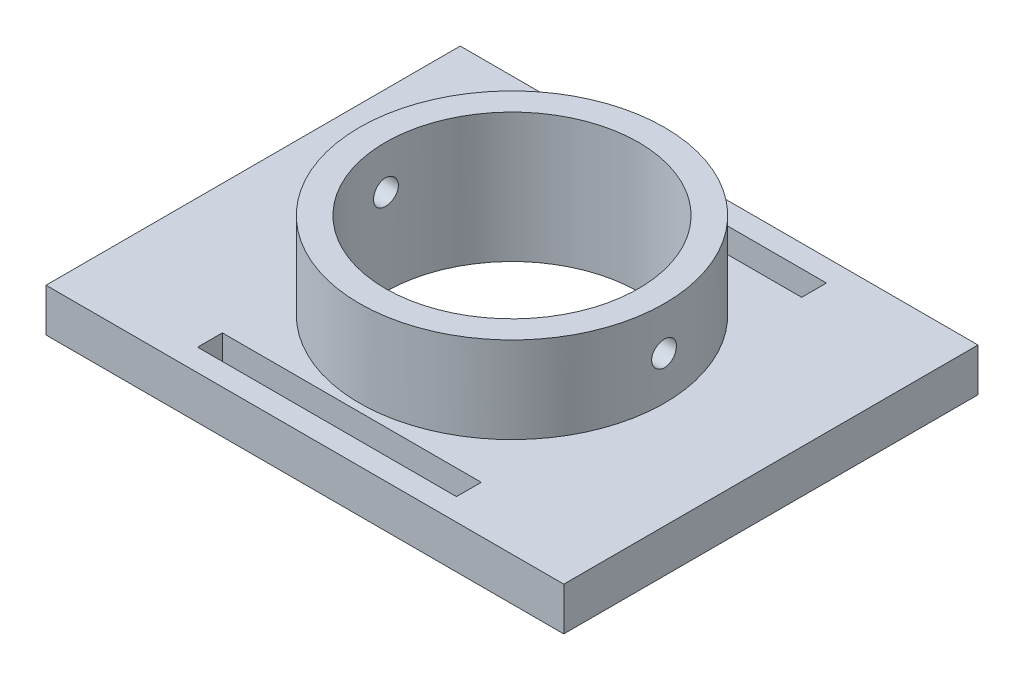
from build123d import *

# Parameters (mm, degrees)
CROQUIS1_W                 = 60
CROQUIS1_H                 = 48
SALIENTE_EXTRUIR1_DEPTH    = 5
CROQUIS2_R                 = 17.675
SALIENTE_EXTRUIR2_DEPTH    = 10
CORTAR_EXTRUIR1_REACH      = 17
CROQUIS3_R                 = 14.675
CROQUIS5_W                 = 30
CROQUIS5_H                 = 2.87
CORTAR_EXTRUIR2_DEPTH      = 6
CROQUIS6_R                 = 1.435
CORTAR_EXTRUIR3_DEPTH      = 31
CORTAR_EXTRUIR3_DEPTH_BACK = 31


with BuildPart() as part:
    # Croquis1 → Saliente-Extruir1 (new body)
    with BuildSketch(Plane(origin=(0, 0, 0), x_dir=(1, 0, 0), z_dir=(0, 1, 0))):
        Rectangle(CROQUIS1_W, CROQUIS1_H)
    extrude(amount=SALIENTE_EXTRUIR1_DEPTH)

    # Croquis2 → Saliente-Extruir2 (add)
    with BuildSketch(Plane(origin=(0, 5, 0), x_dir=(1, 0, 0), z_dir=(0, 1, 0))):
        Circle(CROQUIS2_R)
    extrude(amount=SALIENTE_EXTRUIR2_DEPTH)

    # Croquis3 → Cortar-Extruir1 (cut, up to next)
    with BuildSketch(Plane.XZ, mode=Mode.PRIVATE) as cortar_extruir1_sk1:
        Circle(CROQUIS3_R)
    cortar_extruir1_tool1 = extrude(cortar_extruir1_sk1.sketch, amount=-CORTAR_EXTRUIR1_REACH, mode=Mode.PRIVATE) & part.part
    add(cortar_extruir1_tool1.solids().sort_by_distance((0, 0, 0))[0], mode=Mode.SUBTRACT)

    # Croquis5 → Cortar-Extruir2 (cut, through all)
    with BuildSketch(Plane(origin=(0, 5, 0), x_dir=(1, 0, 0), z_dir=(0, 1, 0))):
        with Locations((0, 20)):
            Rectangle(CROQUIS5_W, CROQUIS5_H)
        with Locations((0, -20)):
            Rectangle(CROQUIS5_W, CROQUIS5_H)
    extrude(amount=-CORTAR_EXTRUIR2_DEPTH, mode=Mode.SUBTRACT)

    # Croquis6 → Cortar-Extruir3 (cut, two sides)
    with BuildSketch(Plane(origin=(0, 0, 0), x_dir=(0, 0, -1), z_dir=(1, 0, 0))) as cortar_extruir3_sk:
        with Locations((0, 10)):
            Circle(CROQUIS6_R)
    extrude(amount=CORTAR_EXTRUIR3_DEPTH, mode=Mode.SUBTRACT)
    extrude(cortar_extruir3_sk.sketch, amount=-CORTAR_EXTRUIR3_DEPTH_BACK, mode=Mode.SUBTRACT)


solid = part.part
